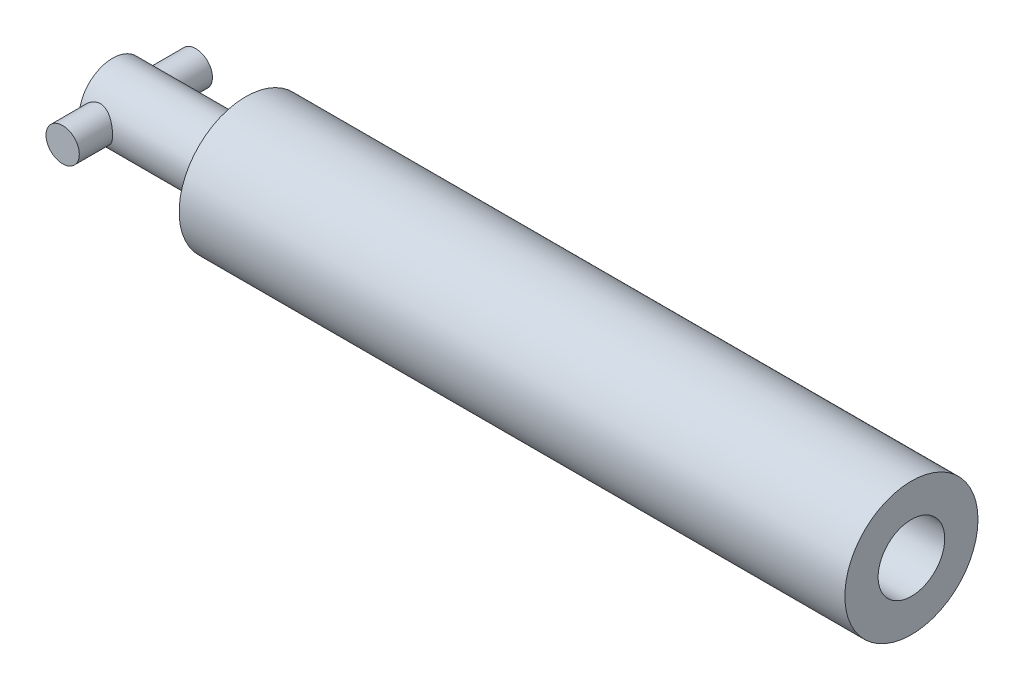
from build123d import *

# Parameters (mm, degrees)
SKETCH1_R           = 25.4
BOSS_EXTRUDE1_DEPTH = 127
SKETCH2_R           = 12.7
BOSS_EXTRUDE2_DEPTH = 50.8
SKETCH3_R           = 6.35
BOSS_EXTRUDE3_DEPTH = 25.4
SKETCH4_R           = 12.7
CUT_EXTRUDE1_DEPTH  = 228.6


with BuildPart() as part:
    # Sketch1 → Boss-Extrude1 (new body, symmetric)
    with BuildSketch(Plane(origin=(0, 0, 0), x_dir=(0, 0, -1), z_dir=(1, 0, 0))):
        Circle(SKETCH1_R)
    extrude(amount=BOSS_EXTRUDE1_DEPTH, both=True)

    # Sketch2 → Boss-Extrude2 (add)
    with BuildSketch(Plane.ZY.offset(127)):
        Circle(SKETCH2_R)
    extrude(amount=BOSS_EXTRUDE2_DEPTH)

    # Sketch3 → Boss-Extrude3 (add, symmetric)
    with BuildSketch(Plane.XY):
        with Locations((-171.45, 0)):
            Circle(SKETCH3_R)
    extrude(amount=BOSS_EXTRUDE3_DEPTH, both=True)

    # Sketch4 → Cut-Extrude1 (cut)
    with BuildSketch(Plane(origin=(127, 0, 0), x_dir=(0, 0, -1), z_dir=(1, 0, 0))):
        Circle(SKETCH4_R)
    extrude(amount=-CUT_EXTRUDE1_DEPTH, mode=Mode.SUBTRACT)


solid = part.part
